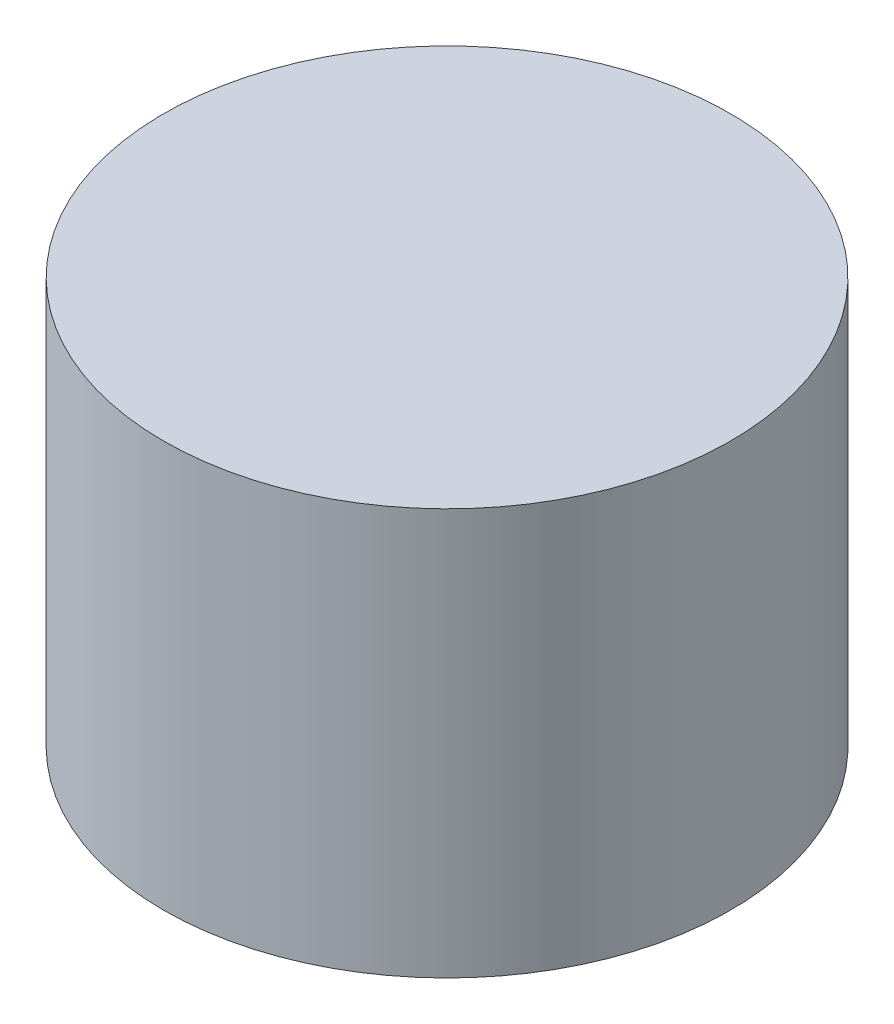
from build123d import *

# Parameters (mm, degrees)
SKETCH1_R           = 15
BOSS_EXTRUDE1_DEPTH = 21.5


with BuildPart() as part:
    # Sketch1 → Boss-Extrude1 (new body)
    with BuildSketch(Plane(origin=(0, 0, 0), x_dir=(1, 0, 0), z_dir=(0, 1, 0))):
        Circle(SKETCH1_R)
    extrude(amount=BOSS_EXTRUDE1_DEPTH)


solid = part.part
